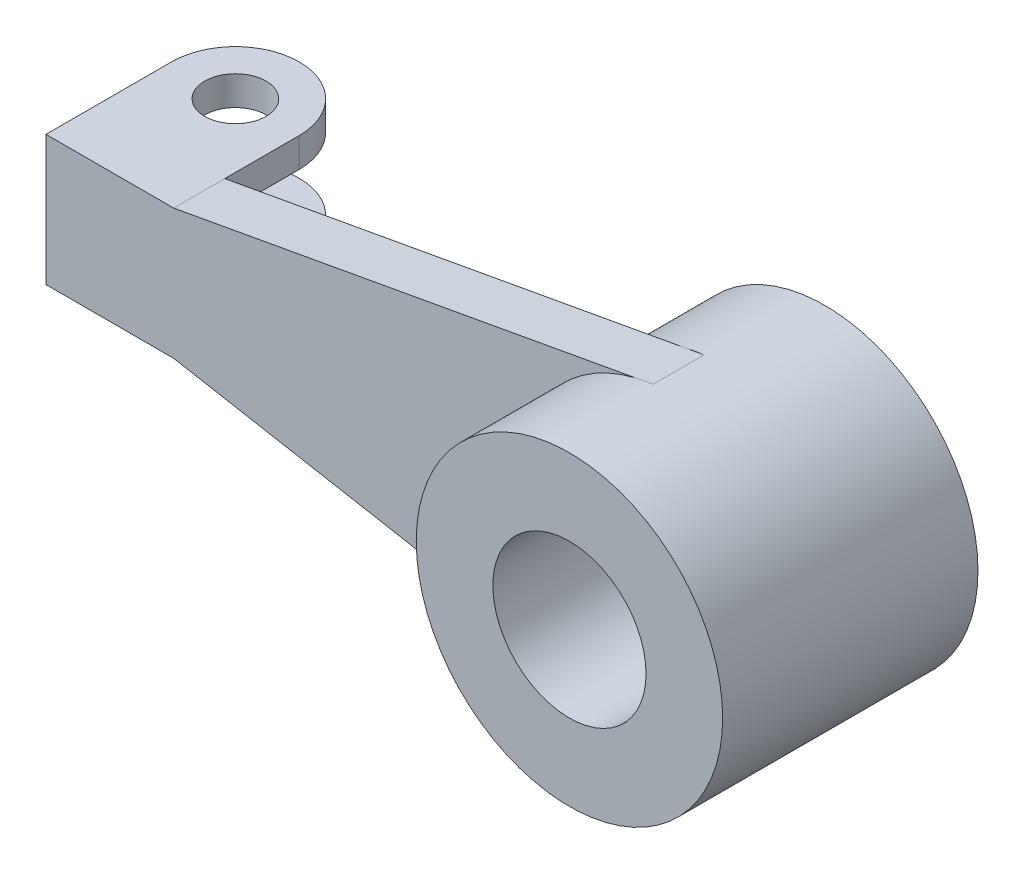
from build123d import *

# Parameters (mm, degrees)
SKETCH1_R           = 150
BOSS_EXTRUDE3_DEPTH = 25
SKETCH6_R           = 300
SKETCH6_R_2         = 150
BOSS_EXTRUDE6_DEPTH = 200
SKETCH9_R           = 60
BOSS_EXTRUDE8_DEPTH = 254.189683417
SKETCH10_W          = 145.864440971
SKETCH10_H          = 70
SKETCH10_W_2        = 154.135559029
CUT_EXTRUDE1_DEPTH  = 300


with BuildPart() as part:
    # Sketch1 → Boss-Extrude3 (new body, symmetric)
    with BuildSketch(Plane.XY):
        with BuildLine():
            Line((179.794520548, 127.397260274), (-70.205479452, 127.397260274))
            Line((-70.205479452, 127.397260274), (-70.205479452, -127.397260274))
            Line((-70.205479452, -127.397260274), (179.794520548, -127.397260274))
            Line((179.794520548, -127.397260274), (1084.183927904, -291.571850847))
            Line((1084.183927904, -291.571850847), (1118.418389374, -297.786462219))
            ThreePointArc((1118.418389374, -297.786462219), (1454.794520548, 0), (1118.418389374, 297.786462219))
            Line((1118.418389374, 297.786462219), (1084.183927904, 291.571850847))
            Line((1084.183927904, 291.571850847), (179.794520548, 127.397260274))
        make_face()
        with Locations((1154.794520548, 0)):
            Circle(SKETCH1_R, mode=Mode.SUBTRACT)
    boss_extrude3 = extrude(amount=BOSS_EXTRUDE3_DEPTH, both=True)

    # Sketch6 → Boss-Extrude6 (add)
    with BuildSketch(Plane.XY.offset(25)):
        with Locations(Location((1154.794520548, 0, 0), (0, 0, 256.386646044))):  # turned: the seam where the file's is
            Circle(SKETCH6_R)
        with Locations((1154.794520548, 0)):
            Circle(SKETCH6_R_2, mode=Mode.SUBTRACT)
    boss_extrude6 = extrude(amount=BOSS_EXTRUDE6_DEPTH)

    # Mirror1: Boss-Extrude3, Boss-Extrude6 across plane
    add(boss_extrude3.mirror(Plane.XY.offset(-25)))
    add(boss_extrude6.mirror(Plane.XY.offset(-25)))

    # Sketch9 → Boss-Extrude8 (add)
    with BuildSketch(Plane(origin=(0, 127.397260274, 0), x_dir=(1, 0, 0), z_dir=(0, 1, 0))):
        with BuildLine():
            Line((179.794520548, 75), (179.794520548, 220.864440971))
            ThreePointArc((179.794520548, 220.864440971), (54.794520548, 345.864440971), (-70.205479452, 220.864440971))
            Line((-70.205479452, 220.864440971), (-70.205479452, 75))
            Line((-70.205479452, 75), (179.794520548, 75))
        make_face()
        with Locations(Location((54.794520548, 220.864440971, 0), (0, 0, 270))):  # turned: the seam where the file's is
            Circle(SKETCH9_R, mode=Mode.SUBTRACT)
    extrude(amount=-BOSS_EXTRUDE8_DEPTH)

    # Sketch10 → Cut-Extrude1 (cut)
    with BuildSketch(Plane.ZY.offset(70.205479452)):
        with Locations((-147.932220486, -35)):
            Rectangle(SKETCH10_W, SKETCH10_H)
        with Locations((-297.932220486, -35)):
            Rectangle(SKETCH10_W_2, SKETCH10_H)
        with Locations((-297.932220486, 35)):
            Rectangle(SKETCH10_W_2, SKETCH10_H)
        with Locations((-147.932220486, 35)):
            Rectangle(SKETCH10_W, SKETCH10_H)
    extrude(amount=-CUT_EXTRUDE1_DEPTH, mode=Mode.SUBTRACT)


solid = part.part
